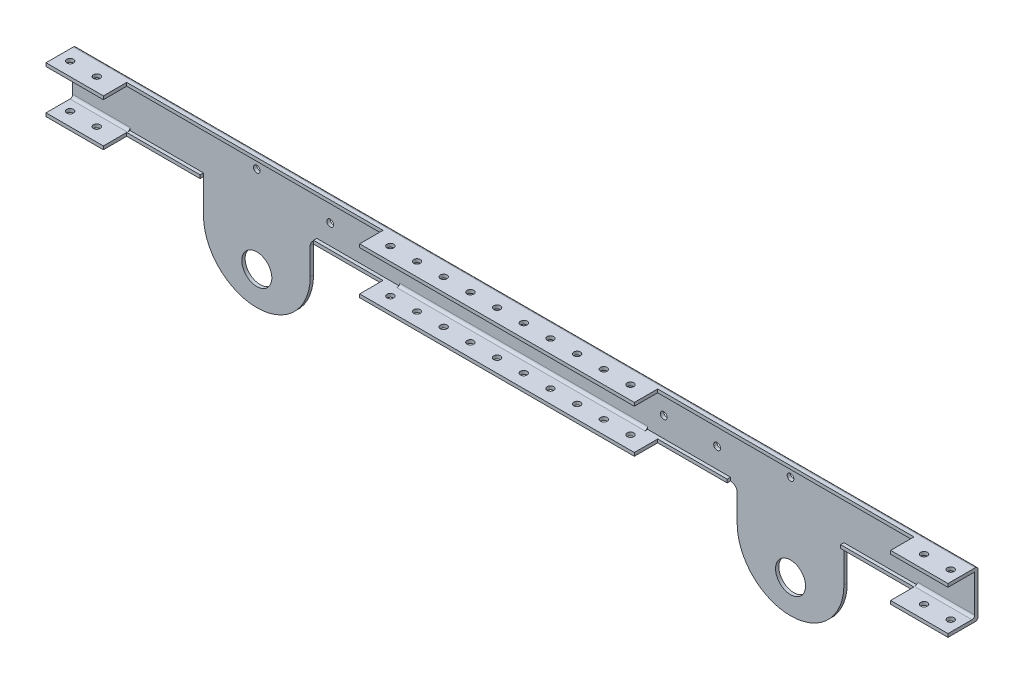
from build123d import *
from build123d.topology import SkipClean

# Parameters (mm, degrees)
SKETCH1_R            = 6.35
BOSS_EXTRUDE1_DEPTH  = 3.175
SKETCH2_W            = 596.9
SKETCH2_H            = 3.175
BOSS_EXTRUDE2_DEPTH  = 25.4
FILLET1_R            = 2.54
SKETCH3_R            = 3.2639
CUT_EXTRUDE1_DEPTH   = 25.4
SKETCH5_R            = 3.2639
CUT_EXTRUDE2_DEPTH   = 25.4
SKETCH6_W            = 31.75
SKETCH6_H            = 44.45
BOSS_EXTRUDE3_DEPTH  = 3.175
SKETCH7_W            = 31.75
SKETCH7_H            = 3.175
SKETCH7_W_2          = 381
BOSS_EXTRUDE4_DEPTH  = 25.4
FILLET2_R            = 2.54
SKETCH8_R            = 3.2639
CUT_EXTRUDE3_DEPTH   = 177.8
SKETCH9_R            = 3.2639
CUT_EXTRUDE5_DEPTH   = 432.308
BOSS_EXTRUDE6_DEPTH  = 66.675
BOSS_EXTRUDE7_START  = 66.675
BOSS_EXTRUDE7_DEPTH  = 66.675
SKETCH12_R           = 6.35
SKETCH12_R_2         = 3.2639
SKETCH12_W           = 256.6289
SKETCH12_H           = 252.715944366
CUT_EXTRUDE8_DEPTH   = 66.675
BOSS_EXTRUDE8_START  = 19.05
BOSS_EXTRUDE8_DEPTH  = 19.05
BOSS_EXTRUDE9_DEPTH  = 19.05
SKETCH16_R           = 3.2639
CUT_EXTRUDE9_DEPTH   = 133.096
SKETCH17_R           = 3.175
CUT_EXTRUDE11_DEPTH  = 5.08
SKETCH18_W           = 256.6289
SKETCH18_H           = 3.175
SKETCH18_W_2         = 838.2
BOSS_EXTRUDE10_DEPTH = 3.175
SKETCH19_W           = 107.950440108
SKETCH19_H           = 6.388661832
SKETCH19_W_2         = 107.95
SKETCH19_H_2         = 3.175
CUT_EXTRUDE12_DEPTH  = 3.175
SKETCH20_W           = 555.272296498
SKETCH20_H           = 244.428342312
SKETCH20_R           = 3.2639
SKETCH20_R_2         = 6.35
SKETCH20_R_3         = 3.175
CUT_EXTRUDE13_DEPTH  = 277.622
BOSS_EXTRUDE11_START = -3.175
SKETCH21_R           = 6.35
BOSS_EXTRUDE11_DEPTH = 3.175
SKETCH22_W           = 47.625
SKETCH22_H           = 22.225
SKETCH22_W_2         = 236.0422
BOSS_EXTRUDE12_DEPTH = 3.175
SKETCH23_W           = 47.625
SKETCH23_H           = 22.225
SKETCH23_W_2         = 236.0422
BOSS_EXTRUDE14_DEPTH = 3.175
BOSS_EXTRUDE15_DEPTH = 12.7
BOSS_EXTRUDE16_START = 12.7
BOSS_EXTRUDE16_DEPTH = 12.7
SKETCH27_R           = 3.175
CUT_EXTRUDE15_DEPTH  = 76.2
SKETCH28_W           = 22.225
SKETCH28_H           = 3.175
BOSS_EXTRUDE17_DEPTH = 12.7
SKETCH29_W           = 22.225
SKETCH29_H           = 3.175
BOSS_EXTRUDE18_DEPTH = 12.7
SKETCH30_R           = 6.321493949
BOSS_EXTRUDE19_DEPTH = 3.175
SKETCH31_R           = 6.35
CUT_EXTRUDE16_DEPTH  = 3.175
SKETCH32_W           = 28.574777667
SKETCH32_H           = 18.699670679
BOSS_EXTRUDE20_DEPTH = 3.175
CUT_EXTRUDE17_START  = -5.715
CUT_EXTRUDE17_DEPTH  = 5.715
CUT_EXTRUDE18_DEPTH  = 5.715
SKETCH35_R           = 14.2875
CUT_EXTRUDE19_DEPTH  = 3.175


with BuildPart() as part:
    # Sketch1 → Boss-Extrude1 (new body)
    with BuildSketch(Plane.XY):
        with BuildLine():
            Line((50.8, 0), (50.8, 25.4))
            ThreePointArc((50.8, 25.4), (52.659871939, 29.890128061), (57.15, 31.75))
            Line((57.15, 31.75), (438.15, 31.75))
            ThreePointArc((438.15, 31.75), (442.640128061, 29.890128061), (444.5, 25.4))
            Line((444.5, 25.4), (444.5, 0))
            ThreePointArc((444.5, 0), (495.3, -50.8), (546.1, 0))
            Line((546.1, 0), (546.1, 76.2))
            Line((546.1, 76.2), (-50.8, 76.2))
            Line((-50.8, 76.2), (-50.8, 0))
            ThreePointArc((-50.8, 0), (0, -50.8), (50.8, 0))
        make_face()
        Circle(SKETCH1_R, mode=Mode.SUBTRACT)
        with Locations((495.3, 0)):
            Circle(SKETCH1_R, mode=Mode.SUBTRACT)
    extrude(amount=BOSS_EXTRUDE1_DEPTH)

    # Sketch2 → Boss-Extrude2 (add)
    with BuildSketch(Plane.XY.offset(3.175)):
        with Locations((247.65, 74.6125)):
            Rectangle(SKETCH2_W, SKETCH2_H)
    extrude(amount=BOSS_EXTRUDE2_DEPTH)

    # Fillet1
    fillet1_edges = [part.edges().sort_by_distance(p)[0] for p in [
        (247.65, 73.025, 3.175),
        (247.65, 76.2, 0),
    ]]
    fillet(fillet1_edges, radius=FILLET1_R)

    # Sketch3 → Cut-Extrude1 (cut)
    with BuildSketch(Plane(origin=(0, 76.2, 0), x_dir=(1, 0, 0), z_dir=(0, 1, 0))):
        with Locations((527.05, -15.5575)):
            Circle(SKETCH3_R)
        with Locations((501.65, -15.5575)):
            Circle(SKETCH3_R)
        with Locations((476.25, -15.5575)):
            Circle(SKETCH3_R)
        with Locations((450.85, -15.5575)):
            Circle(SKETCH3_R)
        with Locations((425.45, -15.5575)):
            Circle(SKETCH3_R)
        with Locations((400.05, -15.5575)):
            Circle(SKETCH3_R)
        with Locations((374.65, -15.5575)):
            Circle(SKETCH3_R)
        with Locations((349.25, -15.5575)):
            Circle(SKETCH3_R)
        with Locations((323.85, -15.5575)):
            Circle(SKETCH3_R)
        with Locations((298.45, -15.5575)):
            Circle(SKETCH3_R)
        with Locations((273.05, -15.5575)):
            Circle(SKETCH3_R)
        with Locations((247.65, -15.5575)):
            Circle(SKETCH3_R)
        with Locations((222.25, -15.5575)):
            Circle(SKETCH3_R)
        with Locations((196.85, -15.5575)):
            Circle(SKETCH3_R)
        with Locations((171.45, -15.5575)):
            Circle(SKETCH3_R)
        with Locations((146.05, -15.5575)):
            Circle(SKETCH3_R)
        with Locations((120.65, -15.5575)):
            Circle(SKETCH3_R)
        with Locations((95.25, -15.5575)):
            Circle(SKETCH3_R)
        with Locations((69.85, -15.5575)):
            Circle(SKETCH3_R)
        with Locations((44.45, -15.5575)):
            Circle(SKETCH3_R)
        with Locations((19.05, -15.5575)):
            Circle(SKETCH3_R)
        with Locations((-6.35, -15.5575)):
            Circle(SKETCH3_R)
        with Locations((-31.75, -15.5575)):
            Circle(SKETCH3_R)
    extrude(amount=-CUT_EXTRUDE1_DEPTH, mode=Mode.SUBTRACT)

    # Sketch5 → Cut-Extrude2 (cut)
    with BuildSketch(Plane(origin=(0, 0, 0), x_dir=(-1, 0, 0), z_dir=(0, 0, -1))):
        with Locations((-425.45, 53.975)):
            Circle(SKETCH5_R)
        with Locations((-374.65, 53.975)):
            Circle(SKETCH5_R)
        with Locations((-323.85, 53.975)):
            Circle(SKETCH5_R)
        with Locations((-273.05, 53.975)):
            Circle(SKETCH5_R)
        with Locations((-222.25, 53.975)):
            Circle(SKETCH5_R)
        with Locations((-171.45, 53.975)):
            Circle(SKETCH5_R)
        with Locations((-120.65, 53.975)):
            Circle(SKETCH5_R)
        with Locations((-69.85, 53.975)):
            Circle(SKETCH5_R)
    extrude(amount=-CUT_EXTRUDE2_DEPTH, mode=Mode.SUBTRACT)

    # Sketch6 → Boss-Extrude3 (add)
    with BuildSketch(Plane.XY.offset(3.175)):
        with Locations((-66.675, 53.975)):
            Rectangle(SKETCH6_W, SKETCH6_H)
        with Locations((561.975, 53.975)):
            Rectangle(SKETCH6_W, SKETCH6_H)
    extrude(amount=-BOSS_EXTRUDE3_DEPTH)

    # Sketch7 → Boss-Extrude4 (add)
    with BuildSketch(Plane.XY.offset(3.175)):
        with Locations((-66.675, 74.6125)):
            Rectangle(SKETCH7_W, SKETCH7_H)
        with Locations((-66.675, 33.3375)):
            Rectangle(SKETCH7_W, SKETCH7_H)
        with Locations((561.975, 74.6125)):
            Rectangle(SKETCH7_W, SKETCH7_H)
        with Locations((561.975, 33.3375)):
            Rectangle(SKETCH7_W, SKETCH7_H)
        with Locations((247.65, 33.3375)):
            Rectangle(SKETCH7_W_2, SKETCH7_H)
    extrude(amount=BOSS_EXTRUDE4_DEPTH)

    # Fillet2
    fillet2_edges = [part.edges().sort_by_distance(p)[0] for p in [
        (-50.8, 15.875, 0),
        (0, -50.8, 0),
        (50.8, 12.7, 0),
        (52.659871939, 29.890128061, 0),
        (546.1, 15.875, 0),
        (495.3, -50.8, 0),
        (444.5, 12.7, 0),
        (442.640128061, 29.890128061, 0),
        (-66.675, 34.925, 3.175),
        (-66.675, 31.75, 0),
        (247.65, 31.75, 0),
        (247.65, 34.925, 3.175),
        (561.975, 34.925, 3.175),
        (561.975, 31.75, 0),
        (561.975, 76.2, 0),
        (-66.675, 76.2, 0),
    ]]
    fillet(fillet2_edges, radius=FILLET2_R)

    # Sketch8 → Cut-Extrude3 (cut)
    with BuildSketch(Plane(origin=(0, 76.2, 0), x_dir=(1, 0, 0), z_dir=(0, 1, 0))):
        with Locations((-31.75, -15.5575)):
            Circle(SKETCH8_R)
        with Locations((-57.15, -15.5575)):
            Circle(SKETCH8_R)
        with Locations((-6.35, -15.5575)):
            Circle(SKETCH8_R)
        with Locations((19.05, -15.5575)):
            Circle(SKETCH8_R)
        with Locations((44.45, -15.5575)):
            Circle(SKETCH8_R)
        with Locations((69.85, -15.5575)):
            Circle(SKETCH8_R)
        with Locations((95.25, -15.5575)):
            Circle(SKETCH8_R)
        with Locations((120.65, -15.5575)):
            Circle(SKETCH8_R)
        with Locations((146.05, -15.5575)):
            Circle(SKETCH8_R)
        with Locations((171.45, -15.5575)):
            Circle(SKETCH8_R)
        with Locations((196.85, -15.5575)):
            Circle(SKETCH8_R)
        with Locations((222.25, -15.5575)):
            Circle(SKETCH8_R)
        with Locations((247.65, -15.5575)):
            Circle(SKETCH8_R)
        with Locations((273.05, -15.5575)):
            Circle(SKETCH8_R)
        with Locations((298.45, -15.5575)):
            Circle(SKETCH8_R)
        with Locations((323.85, -15.5575)):
            Circle(SKETCH8_R)
        with Locations((349.25, -15.5575)):
            Circle(SKETCH8_R)
        with Locations((374.65, -15.5575)):
            Circle(SKETCH8_R)
        with Locations((400.05, -15.5575)):
            Circle(SKETCH8_R)
        with Locations((425.45, -15.5575)):
            Circle(SKETCH8_R)
        with Locations((450.85, -15.5575)):
            Circle(SKETCH8_R)
        with Locations((476.25, -15.5575)):
            Circle(SKETCH8_R)
        with Locations((501.65, -15.5575)):
            Circle(SKETCH8_R)
        with Locations((527.05, -15.5575)):
            Circle(SKETCH8_R)
        with Locations((552.45, -15.5575)):
            Circle(SKETCH8_R)
    extrude(amount=-CUT_EXTRUDE3_DEPTH, mode=Mode.SUBTRACT)

    # Sketch9 → Cut-Extrude5 (cut)
    with BuildSketch(Plane(origin=(0, 76.2, 0), x_dir=(1, 0, 0), z_dir=(0, 1, 0))):
        with BuildLine():
            Line((298.45, -18.8214), (298.45, -28.575))
            Line((298.45, -28.575), (746.392900795, -28.575))
            Line((746.392900795, -28.575), (746.392900795, 89.004110939))
            Line((746.392900795, 89.004110939), (298.45, 89.004110939))
            Line((298.45, 89.004110939), (298.45, -12.2936))
            ThreePointArc((298.45, -12.2936), (301.7139, -15.5575), (298.45, -18.8214))
        make_face()
        with Locations((323.85, -15.5575)):
            Circle(SKETCH9_R, mode=Mode.SUBTRACT)
        with Locations((349.25, -15.5575)):
            Circle(SKETCH9_R, mode=Mode.SUBTRACT)
        with Locations((374.65, -15.5575)):
            Circle(SKETCH9_R, mode=Mode.SUBTRACT)
        with Locations((400.05, -15.5575)):
            Circle(SKETCH9_R, mode=Mode.SUBTRACT)
        with Locations((425.45, -15.5575)):
            Circle(SKETCH9_R, mode=Mode.SUBTRACT)
        with Locations((450.85, -15.5575)):
            Circle(SKETCH9_R, mode=Mode.SUBTRACT)
        with Locations((476.25, -15.5575)):
            Circle(SKETCH9_R, mode=Mode.SUBTRACT)
        with Locations((501.65, -15.5575)):
            Circle(SKETCH9_R, mode=Mode.SUBTRACT)
        with Locations((527.05, -15.5575)):
            Circle(SKETCH9_R, mode=Mode.SUBTRACT)
        with Locations((552.45, -15.5575)):
            Circle(SKETCH9_R, mode=Mode.SUBTRACT)
    extrude(amount=-CUT_EXTRUDE5_DEPTH, mode=Mode.SUBTRACT)

    # Mirror4: part across plane


with BuildPart() as part_1:
    with SkipClean():  # the faces are left unmerged after this step: merging them gives an invalid solid
        add(part.part)
        add(part.part.mirror(Plane(origin=(298.45, -356.108, 0), x_dir=(0, 0, 1), z_dir=(1, 0, 0))))

    # Sketch10 → Boss-Extrude6 (add)
    with SkipClean():  # the faces are left unmerged after this step: merging them gives an invalid solid
        with BuildSketch(Plane.ZY.offset(82.55)):
            with BuildLine():
                Line((0, 73.66), (0, 34.29))
                ThreePointArc((0, 34.29), (0.743948776, 32.493948776), (2.54, 31.75))
                Line((2.54, 31.75), (28.575, 31.75))
                Line((28.575, 31.75), (28.575, 34.925))
                Line((28.575, 34.925), (5.715, 34.925))
                ThreePointArc((5.715, 34.925), (3.918948776, 35.668948776), (3.175, 37.465))
                Line((3.175, 37.465), (3.175, 73.025))
                Line((3.175, 73.025), (28.575, 73.025))
                Line((28.575, 73.025), (28.575, 76.2))
                Line((28.575, 76.2), (2.54, 76.2))
                ThreePointArc((2.54, 76.2), (0.743948776, 75.456051224), (0, 73.66))
            make_face()
        extrude(amount=BOSS_EXTRUDE6_DEPTH)

    # Sketch11 → Boss-Extrude7 (add)
    with SkipClean():  # the faces are left unmerged after this step: merging them gives an invalid solid
        with BuildSketch(Plane(origin=(679.45, 0, 0), x_dir=(0, 0, -1), z_dir=(1, 0, 0)).offset(BOSS_EXTRUDE7_START)):
            with BuildLine():
                Line((0, 34.29), (0, 73.66))
                ThreePointArc((0, 73.66), (-0.743948776, 75.456051224), (-2.54, 76.2))
                Line((-2.54, 76.2), (-28.575, 76.2))
                Line((-28.575, 76.2), (-28.575, 73.025))
                Line((-28.575, 73.025), (-3.175, 73.025))
                Line((-3.175, 73.025), (-3.175, 37.465))
                ThreePointArc((-3.175, 37.465), (-3.918948776, 35.668948776), (-5.715, 34.925))
                Line((-5.715, 34.925), (-28.575, 34.925))
                Line((-28.575, 34.925), (-28.575, 31.75))
                Line((-28.575, 31.75), (-2.54, 31.75))
                ThreePointArc((-2.54, 31.75), (-0.743948776, 32.493948776), (0, 34.29))
            make_face()
        extrude(amount=-BOSS_EXTRUDE7_DEPTH)

    # Sketch12 → Cut-Extrude8 (cut)
    # profile 1 of 2: a face of its own
    with SkipClean():  # the faces are left unmerged after this step: merging them gives an invalid solid
        with BuildSketch(Plane.XY.offset(3.175)):
            with BuildLine():
                Line((135.9789, 114.3), (-120.65, 114.3))
                Line((-120.65, 114.3), (-120.65, -7.986269461))
                Line((-120.65, -7.986269461), (-114.3, -7.986269461))
                Line((-114.3, -7.986269461), (-114.3, 0))
                ThreePointArc((-114.3, 0), (0, -114.3), (114.3, 0))
                Line((114.3, 0), (114.3, -15.458780647))
                Line((114.3, -15.458780647), (135.9789, -15.458780647))
                Line((135.9789, -15.458780647), (135.9789, 114.3))
            make_face()
            Circle(SKETCH12_R, mode=Mode.SUBTRACT)
            with Locations((69.85, 53.975)):
                Circle(SKETCH12_R_2, mode=Mode.SUBTRACT)
            with Locations((120.65, 53.975)):
                Circle(SKETCH12_R_2, mode=Mode.SUBTRACT)
        # profile 2 of 2: a face of its own
        with BuildSketch(Plane.XY.offset(3.175)):
            with Locations((589.23555, 8.748218221)):
                Rectangle(SKETCH12_W, SKETCH12_H)
            with Locations((596.9, 0)):
                Circle(SKETCH12_R, mode=Mode.SUBTRACT)
            with Locations((476.25, 53.975)):
                Circle(SKETCH12_R_2, mode=Mode.SUBTRACT)
            with Locations((527.05, 53.975)):
                Circle(SKETCH12_R_2, mode=Mode.SUBTRACT)
        extrude(amount=CUT_EXTRUDE8_DEPTH, mode=Mode.SUBTRACT)

    # Sketch14 → Boss-Extrude8 (add)
    with SkipClean():  # the faces are left unmerged after this step: merging them gives an invalid solid
        with BuildSketch(Plane(origin=(746.125, 0, 0), x_dir=(0, 0, -1), z_dir=(1, 0, 0)).offset(BOSS_EXTRUDE8_START)):
            with BuildLine():
                Line((0, 34.29), (0, 73.66))
                ThreePointArc((0, 73.66), (-0.743948776, 75.456051224), (-2.54, 76.2))
                Line((-2.54, 76.2), (-28.575, 76.2))
                Line((-28.575, 76.2), (-28.575, 73.025))
                Line((-28.575, 73.025), (-3.175, 73.025))
                Line((-3.175, 73.025), (-3.175, 37.465))
                ThreePointArc((-3.175, 37.465), (-3.918948776, 35.668948776), (-5.715, 34.925))
                Line((-5.715, 34.925), (-28.575, 34.925))
                Line((-28.575, 34.925), (-28.575, 31.75))
                Line((-28.575, 31.75), (-2.54, 31.75))
                ThreePointArc((-2.54, 31.75), (-0.743948776, 32.493948776), (0, 34.29))
            make_face()
        extrude(amount=-BOSS_EXTRUDE8_DEPTH)

    # Sketch15 → Boss-Extrude9 (add)
    with SkipClean():  # the faces are left unmerged after this step: merging them gives an invalid solid
        with BuildSketch(Plane.ZY.offset(149.225)):
            with BuildLine():
                Line((0, 73.66), (0, 34.29))
                ThreePointArc((0, 34.29), (0.743948776, 32.493948776), (2.54, 31.75))
                Line((2.54, 31.75), (28.575, 31.75))
                Line((28.575, 31.75), (28.575, 34.925))
                Line((28.575, 34.925), (5.715, 34.925))
                ThreePointArc((5.715, 34.925), (3.918948776, 35.668948776), (3.175, 37.465))
                Line((3.175, 37.465), (3.175, 73.025))
                Line((3.175, 73.025), (28.575, 73.025))
                Line((28.575, 73.025), (28.575, 76.2))
                Line((28.575, 76.2), (2.54, 76.2))
                ThreePointArc((2.54, 76.2), (0.743948776, 75.456051224), (0, 73.66))
            make_face()
        extrude(amount=BOSS_EXTRUDE9_DEPTH)

    # Sketch16 → Cut-Extrude9 (cut)
    with SkipClean():  # the faces are left unmerged after this step: merging them gives an invalid solid
        with BuildSketch(Plane(origin=(0, 76.2, 0), x_dir=(1, 0, 0), z_dir=(0, 1, 0))):
            with Locations((146.05, -15.5575)):
                Circle(SKETCH16_R)
            with Locations((171.45, -15.5575)):
                Circle(SKETCH16_R)
            with Locations((196.85, -15.5575)):
                Circle(SKETCH16_R)
            with Locations((222.25, -15.5575)):
                Circle(SKETCH16_R)
            with Locations((247.65, -15.5575)):
                Circle(SKETCH16_R)
            with Locations((273.05, -15.5575)):
                Circle(SKETCH16_R)
            with Locations((298.45, -15.5575)):
                Circle(SKETCH16_R)
            with Locations((323.85, -15.5575)):
                Circle(SKETCH16_R)
            with Locations((349.25, -15.5575)):
                Circle(SKETCH16_R)
            with Locations((374.65, -15.5575)):
                Circle(SKETCH16_R)
            with Locations((400.05, -15.5575)):
                Circle(SKETCH16_R)
            with Locations((425.45, -15.5575)):
                Circle(SKETCH16_R)
            with Locations((450.85, -15.5575)):
                Circle(SKETCH16_R)
            with Locations((476.25, -15.5575)):
                Circle(SKETCH16_R)
            with Locations((501.65, -15.5575)):
                Circle(SKETCH16_R)
            with Locations((527.05, -15.5575)):
                Circle(SKETCH16_R)
            with Locations((552.45, -15.5575)):
                Circle(SKETCH16_R)
            with Locations((577.85, -15.5575)):
                Circle(SKETCH16_R)
            with Locations((603.25, -15.5575)):
                Circle(SKETCH16_R)
            with Locations((628.65, -15.5575)):
                Circle(SKETCH16_R)
            with Locations((654.05, -15.5575)):
                Circle(SKETCH16_R)
            with Locations((679.45, -15.5575)):
                Circle(SKETCH16_R)
            with Locations((704.85, -15.5575)):
                Circle(SKETCH16_R)
            with Locations((730.25, -15.5575)):
                Circle(SKETCH16_R)
            with Locations((755.65, -15.5575)):
                Circle(SKETCH16_R)
            with Locations((120.65, -15.5575)):
                Circle(SKETCH16_R)
            with Locations((95.25, -15.5575)):
                Circle(SKETCH16_R)
            with Locations((69.85, -15.5575)):
                Circle(SKETCH16_R)
            with Locations((44.45, -15.5575)):
                Circle(SKETCH16_R)
            with Locations((19.05, -15.5575)):
                Circle(SKETCH16_R)
            with Locations((-6.35, -15.5575)):
                Circle(SKETCH16_R)
            with Locations((-31.75, -15.5575)):
                Circle(SKETCH16_R)
            with Locations((-57.15, -15.5575)):
                Circle(SKETCH16_R)
            with Locations((-82.55, -15.5575)):
                Circle(SKETCH16_R)
            with Locations((-107.95, -15.5575)):
                Circle(SKETCH16_R)
            with Locations((-133.35, -15.5575)):
                Circle(SKETCH16_R)
            with Locations((-158.75, -15.5575)):
                Circle(SKETCH16_R)
        extrude(amount=-CUT_EXTRUDE9_DEPTH, mode=Mode.SUBTRACT)

    # Sketch17 → Cut-Extrude11 (cut)
    with SkipClean():  # the faces are left unmerged after this step: merging them gives an invalid solid
        with BuildSketch(Plane(origin=(0, 0, 0), x_dir=(-1, 0, 0), z_dir=(0, 0, -1))):
            with Locations((0, 63.5)):
                Circle(SKETCH17_R)
            with Locations((-596.9, 63.5)):
                Circle(SKETCH17_R)
        extrude(amount=-CUT_EXTRUDE11_DEPTH, mode=Mode.SUBTRACT)

    # Sketch18 → Boss-Extrude10 (add)
    with SkipClean():  # the faces are left unmerged after this step: merging them gives an invalid solid
        with BuildSketch(Plane.XY.offset(3.175)):
            with Locations((7.66445, 74.6125)):
                Rectangle(SKETCH18_W, SKETCH18_H)
            with Locations((589.23555, 74.6125)):
                Rectangle(SKETCH18_W, SKETCH18_H)
            with Locations((298.45, 33.3375)):
                Rectangle(SKETCH18_W_2, SKETCH18_H)
        extrude(amount=BOSS_EXTRUDE10_DEPTH)

    # Sketch19 → Cut-Extrude12 (cut)
    with SkipClean():  # the faces are left unmerged after this step: merging them gives an invalid solid
        with BuildSketch(Plane.XY.offset(3.175)):
            with Locations((3.175220054, 34.944330916)):
                Rectangle(SKETCH19_W, SKETCH19_H)
            with Locations((593.725, 33.3375)):
                Rectangle(SKETCH19_W_2, SKETCH19_H_2)
        extrude(amount=CUT_EXTRUDE12_DEPTH, mode=Mode.SUBTRACT)

    # Sketch20 → Cut-Extrude13 (cut)
    with BuildSketch(Plane(origin=(0, 0, 0), x_dir=(-1, 0, 0), z_dir=(0, 0, -1))):
        with Locations((-65.263851751, 61.916295681)):
            Rectangle(SKETCH20_W, SKETCH20_H)
        with Locations((-323.85, 53.975)):
            Circle(SKETCH20_R, mode=Mode.SUBTRACT)
        with Locations((-273.05, 53.975)):
            Circle(SKETCH20_R, mode=Mode.SUBTRACT)
        with Locations((-222.25, 53.975)):
            Circle(SKETCH20_R, mode=Mode.SUBTRACT)
        with Locations((-171.45, 53.975)):
            Circle(SKETCH20_R, mode=Mode.SUBTRACT)
        with Locations((-120.65, 53.975)):
            Circle(SKETCH20_R, mode=Mode.SUBTRACT)
        with Locations((-69.85, 53.975)):
            Circle(SKETCH20_R, mode=Mode.SUBTRACT)
        Circle(SKETCH20_R_2, mode=Mode.SUBTRACT)
        with Locations((0, 63.5)):
            Circle(SKETCH20_R_3, mode=Mode.SUBTRACT)
    extrude(amount=-CUT_EXTRUDE13_DEPTH, mode=Mode.SUBTRACT)

    # Sketch21 → Boss-Extrude11 (add)
    with BuildSketch(Plane.XY.offset(3.175).offset(BOSS_EXTRUDE11_START)):
        with BuildLine():
            Line((546.1, 0), (546.1, 25.4))
            ThreePointArc((546.1, 25.4), (544.240128061, 29.890128061), (539.75, 31.75))
            Line((539.75, 31.75), (539.75, 34.925))
            Line((539.75, 34.925), (647.7, 34.925))
            Line((647.7, 34.925), (647.7, 31.75))
            Line((647.7, 31.75), (647.7, 0))
            ThreePointArc((647.7, 0), (596.9, -50.8), (546.1, 0))
        make_face()
        with Locations((596.9, 0)):
            Circle(SKETCH21_R, mode=Mode.SUBTRACT)
    extrude(amount=BOSS_EXTRUDE11_DEPTH)

    # Mirror5: part across plane


with BuildPart() as part_2:
    add(part_1.part)
    add(part_1.part.mirror(Plane(origin=(342.9, 0, 277.622), x_dir=(0, 0, 1), z_dir=(1, 0, 0))))

    # Sketch22 → Boss-Extrude12 (add)
    with BuildSketch(Plane(origin=(0, 76.2, 0), x_dir=(1, 0, 0), z_dir=(0, 1, 0))):
        with Locations((741.3625, -17.4625)):
            Rectangle(SKETCH22_W, SKETCH22_H)
        with Locations((342.9, -17.4625)):
            Rectangle(SKETCH22_W_2, SKETCH22_H)
        with Locations((-55.5625, -17.4625)):
            Rectangle(SKETCH22_W, SKETCH22_H)
    extrude(amount=-BOSS_EXTRUDE12_DEPTH)

    # Sketch23 → Boss-Extrude14 (add)
    with BuildSketch(Plane.XZ.offset(-31.75)):
        with Locations((-55.5625, 17.4625)):
            Rectangle(SKETCH23_W, SKETCH23_H)
        with Locations((342.9, 17.4625)):
            Rectangle(SKETCH23_W_2, SKETCH23_H)
        with Locations((741.3625, 17.4625)):
            Rectangle(SKETCH23_W, SKETCH23_H)
    extrude(amount=-BOSS_EXTRUDE14_DEPTH)

    # Sketch25 → Boss-Extrude15 (add)
    with BuildSketch(Plane.ZY.offset(79.375)):
        with BuildLine():
            Line((2.54, 31.75), (28.575, 31.75))
            Line((28.575, 31.75), (28.575, 34.925))
            Line((28.575, 34.925), (5.715, 34.925))
            ThreePointArc((5.715, 34.925), (3.918948776, 35.668948776), (3.175, 37.465))
            Line((3.175, 37.465), (3.175, 73.025))
            Line((3.175, 73.025), (28.575, 73.025))
            Line((28.575, 73.025), (28.575, 76.2))
            Line((28.575, 76.2), (2.54, 76.2))
            ThreePointArc((2.54, 76.2), (0.743948776, 75.456051224), (0, 73.66))
            Line((0, 73.66), (0, 34.29))
            ThreePointArc((0, 34.29), (0.743948776, 32.493948776), (2.54, 31.75))
        make_face()
    extrude(amount=BOSS_EXTRUDE15_DEPTH)

    # Sketch26 → Boss-Extrude16 (add)
    with BuildSketch(Plane(origin=(765.175, 0, 0), x_dir=(0, 0, -1), z_dir=(1, 0, 0)).offset(BOSS_EXTRUDE16_START)):
        with BuildLine():
            Line((-5.715, 34.925), (-28.575, 34.925))
            Line((-28.575, 34.925), (-28.575, 31.75))
            Line((-28.575, 31.75), (-2.54, 31.75))
            ThreePointArc((-2.54, 31.75), (-0.743948776, 32.493948776), (0, 34.29))
            Line((0, 34.29), (0, 73.66))
            ThreePointArc((0, 73.66), (-0.743948776, 75.456051224), (-2.54, 76.2))
            Line((-2.54, 76.2), (-28.575, 76.2))
            Line((-28.575, 76.2), (-28.575, 73.025))
            Line((-28.575, 73.025), (-3.175, 73.025))
            Line((-3.175, 73.025), (-3.175, 37.465))
            ThreePointArc((-3.175, 37.465), (-3.918948776, 35.668948776), (-5.715, 34.925))
        make_face()
    extrude(amount=-BOSS_EXTRUDE16_DEPTH)

    # Sketch27 → Cut-Extrude15 (cut)
    with BuildSketch(Plane(origin=(0, 76.2, 0), x_dir=(1, 0, 0), z_dir=(0, 1, 0))):
        with Locations((762, -15.788044632)):
            Circle(SKETCH27_R)
        with Locations((736.6, -15.788044632)):
            Circle(SKETCH27_R)
        with Locations((711.2, -15.788044632)):
            Circle(SKETCH27_R)
        with Locations((685.8, -15.788044632)):
            Circle(SKETCH27_R)
        with Locations((660.4, -15.788044632)):
            Circle(SKETCH27_R)
        with Locations((635, -15.788044632)):
            Circle(SKETCH27_R)
        with Locations((609.6, -15.788044632)):
            Circle(SKETCH27_R)
        with Locations((584.2, -15.788044632)):
            Circle(SKETCH27_R)
        with Locations((558.8, -15.788044632)):
            Circle(SKETCH27_R)
        with Locations((533.4, -15.788044632)):
            Circle(SKETCH27_R)
        with Locations((508, -15.788044632)):
            Circle(SKETCH27_R)
        with Locations((482.6, -15.788044632)):
            Circle(SKETCH27_R)
        with Locations((457.2, -15.788044632)):
            Circle(SKETCH27_R)
        with Locations((431.8, -15.788044632)):
            Circle(SKETCH27_R)
        with Locations((406.4, -15.788044632)):
            Circle(SKETCH27_R)
        with Locations((381, -15.788044632)):
            Circle(SKETCH27_R)
        with Locations((355.6, -15.788044632)):
            Circle(SKETCH27_R)
        with Locations((330.2, -15.788044632)):
            Circle(SKETCH27_R)
        with Locations((304.8, -15.788044632)):
            Circle(SKETCH27_R)
        with Locations((279.4, -15.788044632)):
            Circle(SKETCH27_R)
        with Locations((254, -15.788044632)):
            Circle(SKETCH27_R)
        with Locations((228.6, -15.788044632)):
            Circle(SKETCH27_R)
        with Locations((203.2, -15.788044632)):
            Circle(SKETCH27_R)
        with Locations((177.8, -15.788044632)):
            Circle(SKETCH27_R)
        with Locations((152.4, -15.788044632)):
            Circle(SKETCH27_R)
        with Locations((127, -15.788044632)):
            Circle(SKETCH27_R)
        with Locations((101.6, -15.788044632)):
            Circle(SKETCH27_R)
        with Locations((76.2, -15.788044632)):
            Circle(SKETCH27_R)
        with Locations((50.8, -15.788044632)):
            Circle(SKETCH27_R)
        with Locations((25.4, -15.788044632)):
            Circle(SKETCH27_R)
        with Locations((0, -15.788044632)):
            Circle(SKETCH27_R)
        with Locations((-25.4, -15.788044632)):
            Circle(SKETCH27_R)
        with Locations((-50.8, -15.788044632)):
            Circle(SKETCH27_R)
        with Locations((-76.2, -15.788044632)):
            Circle(SKETCH27_R)
    extrude(amount=-CUT_EXTRUDE15_DEPTH, mode=Mode.SUBTRACT)

    # Sketch28 → Boss-Extrude17 (add)
    with BuildSketch(Plane.ZY.offset(-224.8789)):
        with Locations((17.4625, 74.6125)):
            Rectangle(SKETCH28_W, SKETCH28_H)
        with Locations((17.4625, 33.3375)):
            Rectangle(SKETCH28_W, SKETCH28_H)
    extrude(amount=BOSS_EXTRUDE17_DEPTH)

    # Sketch29 → Boss-Extrude18 (add)
    with BuildSketch(Plane(origin=(460.9211, 0, 0), x_dir=(0, 0, -1), z_dir=(1, 0, 0))):
        with Locations((-17.4625, 74.6125)):
            Rectangle(SKETCH29_W, SKETCH29_H)
        with Locations((-17.4625, 33.3375)):
            Rectangle(SKETCH29_W, SKETCH29_H)
    extrude(amount=BOSS_EXTRUDE18_DEPTH)

    # Sketch30 → Boss-Extrude19 (add)
    with BuildSketch(Plane.XY.offset(3.175)):
        with Locations((87.64816817, -19.05)):
            Circle(SKETCH30_R)
        Polygon((71.867948908, 15.024467729), (76.689488805, -7.576500536), (114.056423003, -16.014195355), (104.111996966, 17.133891434), align=None)
    extrude(amount=-BOSS_EXTRUDE19_DEPTH)

    # Sketch31 → Cut-Extrude16 (cut)
    with BuildSketch(Plane.XY.offset(3.175)):
        with Locations((88.9, -19.05)):
            Circle(SKETCH31_R)
        with Locations((596.9, -19.05)):
            Circle(SKETCH31_R)
    extrude(amount=-CUT_EXTRUDE16_DEPTH, mode=Mode.SUBTRACT)

    # Sketch32 → Boss-Extrude20 (add)
    with BuildSketch(Plane.XY.offset(3.175)):
        with Locations((601.058442049, 1.748623875)):
            Rectangle(SKETCH32_W, SKETCH32_H)
    extrude(amount=-BOSS_EXTRUDE20_DEPTH)

    # Sketch33 → Cut-Extrude17 (cut)
    with BuildSketch(Plane.ZY.offset(92.075).offset(CUT_EXTRUDE17_START)):
        with BuildLine():
            Line((2.54, 31.75), (28.575, 31.75))
            Line((28.575, 31.75), (28.575, 34.925))
            Line((28.575, 34.925), (5.715, 34.925))
            ThreePointArc((5.715, 34.925), (3.918948776, 35.668948776), (3.175, 37.465))
            Line((3.175, 37.465), (3.175, 73.025))
            Line((3.175, 73.025), (28.575, 73.025))
            Line((28.575, 73.025), (28.575, 76.2))
            Line((28.575, 76.2), (2.54, 76.2))
            ThreePointArc((2.54, 76.2), (0.743948776, 75.456051224), (0, 73.66))
            Line((0, 73.66), (0, 34.29))
            ThreePointArc((0, 34.29), (0.743948776, 32.493948776), (2.54, 31.75))
        make_face()
    extrude(amount=CUT_EXTRUDE17_DEPTH, mode=Mode.SUBTRACT)

    # Sketch34 → Cut-Extrude18 (cut)
    with BuildSketch(Plane(origin=(777.875, 0, 0), x_dir=(0, 0, -1), z_dir=(1, 0, 0))):
        with BuildLine():
            Line((-5.715, 34.925), (-28.575, 34.925))
            Line((-28.575, 34.925), (-28.575, 31.75))
            Line((-28.575, 31.75), (-2.54, 31.75))
            ThreePointArc((-2.54, 31.75), (-0.743948776, 32.493948776), (0, 34.29))
            Line((0, 34.29), (0, 73.66))
            ThreePointArc((0, 73.66), (-0.743948776, 75.456051224), (-2.54, 76.2))
            Line((-2.54, 76.2), (-28.575, 76.2))
            Line((-28.575, 76.2), (-28.575, 73.025))
            Line((-28.575, 73.025), (-3.175, 73.025))
            Line((-3.175, 73.025), (-3.175, 37.465))
            ThreePointArc((-3.175, 37.465), (-3.918948776, 35.668948776), (-5.715, 34.925))
        make_face()
    extrude(amount=-CUT_EXTRUDE18_DEPTH, mode=Mode.SUBTRACT)

    # Sketch35 → Cut-Extrude19 (cut)
    with BuildSketch(Plane(origin=(0, 0, 0), x_dir=(-1, 0, 0), z_dir=(0, 0, -1))):
        with Locations((-596.9, -19.05)):
            Circle(SKETCH35_R)
        with Locations((-88.9, -19.05)):
            Circle(SKETCH35_R)
    extrude(amount=-CUT_EXTRUDE19_DEPTH, mode=Mode.SUBTRACT)


solid = part_2.part
